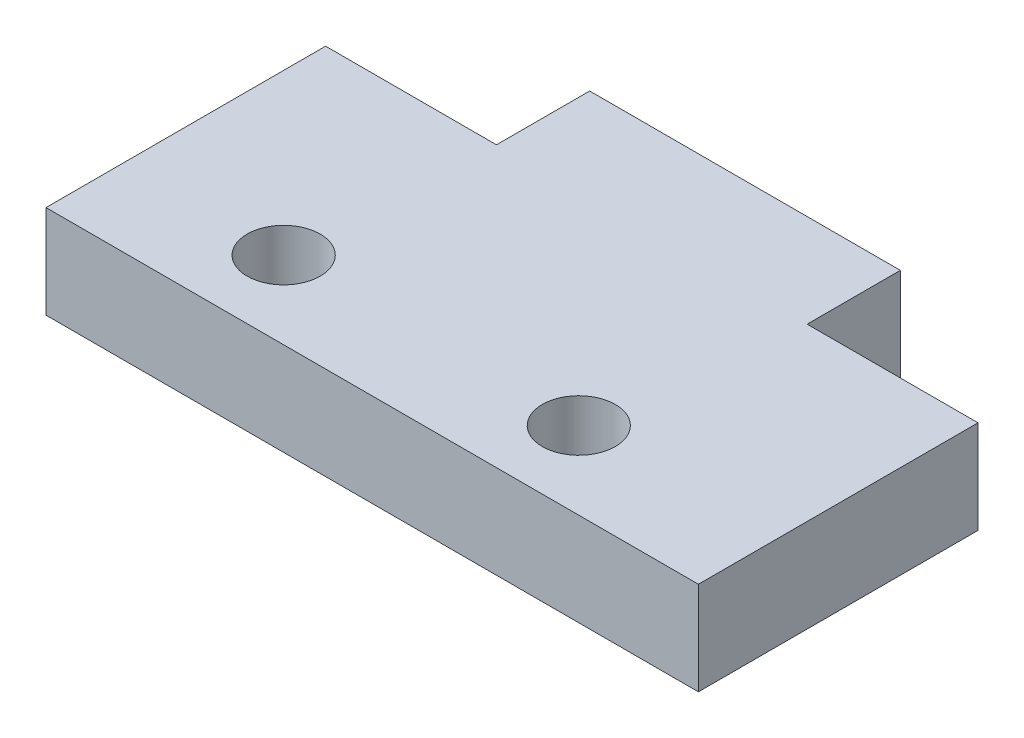
from build123d import *

# Parameters (mm, degrees)
CROQUIS1_R              = 1.175
SALIENTE_EXTRUIR1_DEPTH = 3


with BuildPart() as part:
    # Croquis1 → Saliente-Extruir1 (new body)
    with BuildSketch(Plane(origin=(0, 0, 0), x_dir=(1, 0, 0), z_dir=(0, 1, 0))):
        Polygon((0, 0), (10, 0), (10, -3), (15.5, -3), (15.5, -12), (-5.5, -12), (-5.5, -3), (0, -3), align=None)
        with Locations((-0.35, -9.5)):
            Circle(CROQUIS1_R, mode=Mode.SUBTRACT)
        with Locations((9.15, -9.5)):
            Circle(CROQUIS1_R, mode=Mode.SUBTRACT)
    extrude(amount=SALIENTE_EXTRUIR1_DEPTH)


solid = part.part
